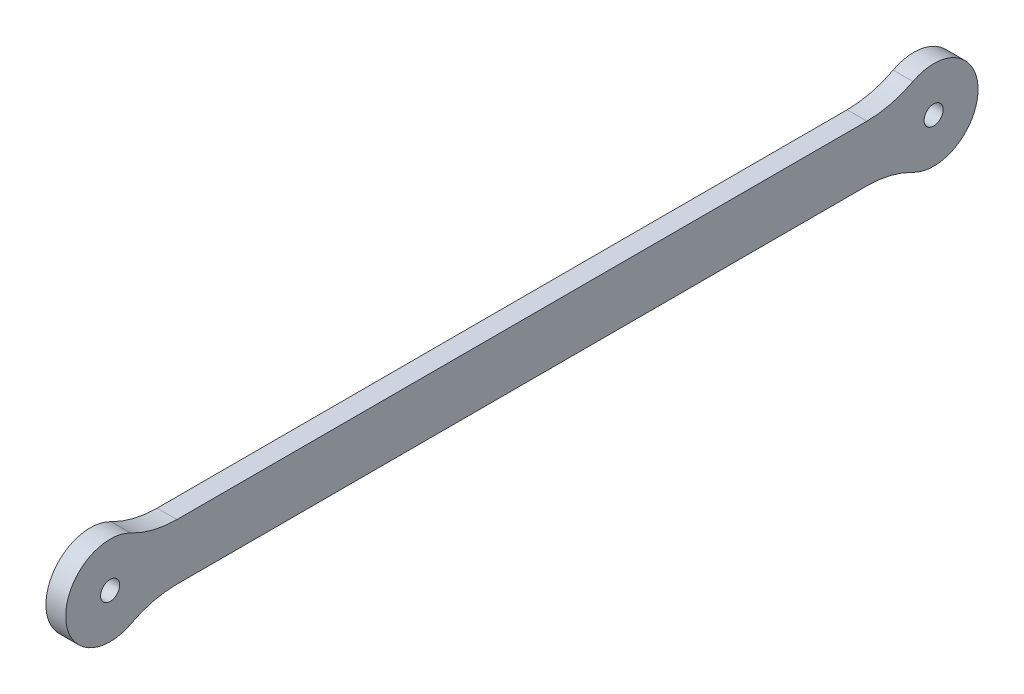
from build123d import *

# Parameters (mm, degrees)
SKETCH1_R           = 6.75
SKETCH1_R_2         = 1.45
BOSS_EXTRUDE1_DEPTH = 1.5
FILLET1_R           = 15


with BuildPart() as part:
    # Sketch1 → Boss-Extrude1 (new body, symmetric)
    with BuildSketch(Plane(origin=(0, 0, 0), x_dir=(0, 0, -1), z_dir=(1, 0, 0))):
        with Locations((-62.5, 0)):
            Circle(SKETCH1_R)
        with Locations((-62.5, 0)):
            Circle(SKETCH1_R_2, mode=Mode.SUBTRACT)
        with BuildLine():
            Line((-57.255955759, -4.25), (57.255955759, -4.25))
            ThreePointArc((57.255955759, -4.25), (55.75, 0), (57.255955759, 4.25))
            Line((57.255955759, 4.25), (-57.255955759, 4.25))
            ThreePointArc((-57.255955759, 4.25), (-56.137618424, 2.254462394), (-55.75, 0))
            ThreePointArc((-55.75, 0), (-56.137618424, -2.254462394), (-57.255955759, -4.25))
        make_face()
        with Locations((62.5, 0)):
            Circle(SKETCH1_R)
        with Locations((62.5, 0)):
            Circle(SKETCH1_R_2, mode=Mode.SUBTRACT)
    extrude(amount=BOSS_EXTRUDE1_DEPTH, both=True)

    # Fillet1
    fillet1_edges = [part.edges().sort_by_distance(p)[0] for p in [
        (0, 4.25, -57.255955759),
        (0, -4.25, -57.255955759),
        (0, -4.25, 57.255955759),
        (0, 4.25, 57.255955759),
    ]]
    fillet(fillet1_edges, radius=FILLET1_R)


solid = part.part
